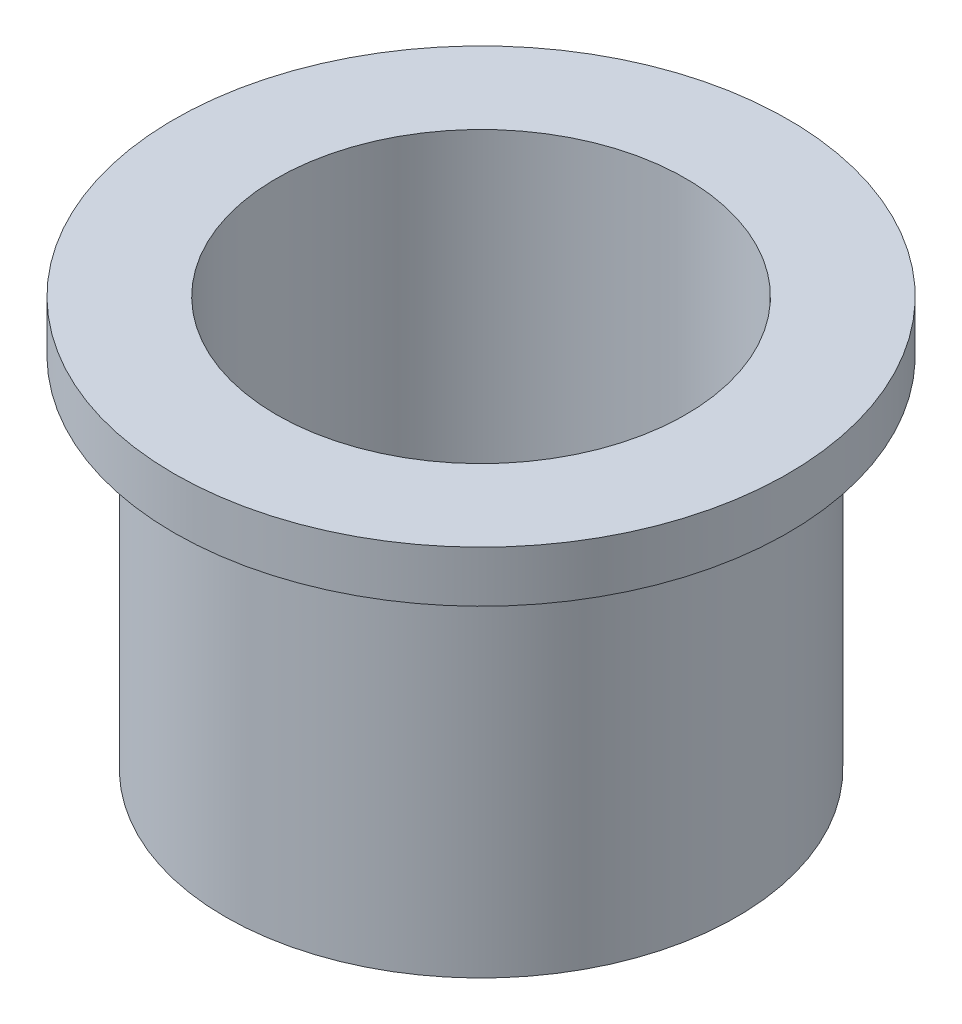
from build123d import *

# Parameters (mm, degrees)
SKETCH1_R           = 7.9375
SKETCH1_R_2         = 6.35
BOSS_EXTRUDE1_DEPTH = 12.7
SKETCH2_R           = 9.525
SKETCH2_R_2         = 6.35
BOSS_EXTRUDE2_DEPTH = 1.5875


with BuildPart() as part:
    # Sketch1 → Boss-Extrude1 (new body)
    with BuildSketch(Plane(origin=(0, 0, 0), x_dir=(1, 0, 0), z_dir=(0, 1, 0))):
        Circle(SKETCH1_R)
        Circle(SKETCH1_R_2, mode=Mode.SUBTRACT)
    extrude(amount=BOSS_EXTRUDE1_DEPTH)

    # Sketch2 → Boss-Extrude2 (add)
    with BuildSketch(Plane(origin=(0, 12.7, 0), x_dir=(1, 0, 0), z_dir=(0, 1, 0))):
        Circle(SKETCH2_R)
        Circle(SKETCH2_R_2, mode=Mode.SUBTRACT)
    extrude(amount=-BOSS_EXTRUDE2_DEPTH)


solid = part.part
